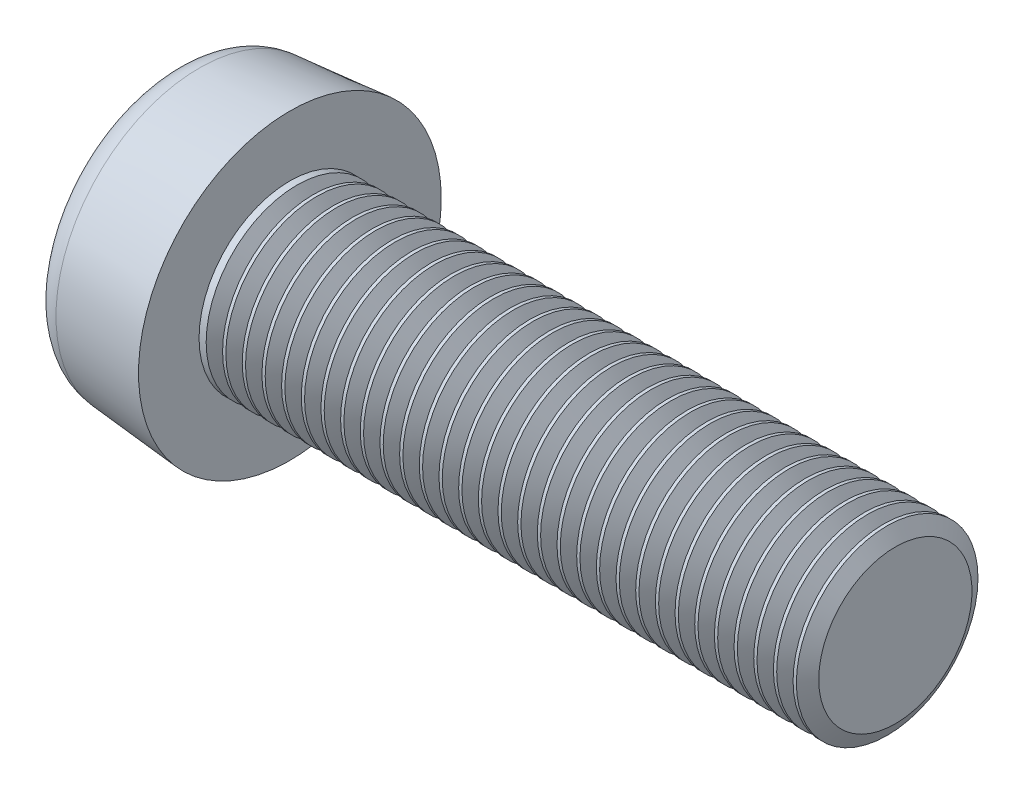
from build123d import *

# Parameters (mm, degrees)
SKETCH1_R        = 5
BASEHEAD_DEPTH   = 3.9
BASEHEAD_DRAFT   = -5
SKETCH8_W        = 20
SKETCH8_H        = 3
SOCKET_DEPTH     = 2
HEADFILLET2_R    = 1
LPATTERN10_COUNT = 31
LPATTERN10_PITCH = 0.6498


with BuildPart() as part:
    # Sketch1 → BaseHead (with draft: the straight prism first)
    with BuildSketch(Plane(origin=(3.9, 0, 0), x_dir=(0, 0, -1), z_dir=(1, 0, 0))):
        Circle(SKETCH1_R)
    extrude(amount=-BASEHEAD_DEPTH)
    # BaseHead: the draft: its side faces are tilted about the plane it starts from
    basehead_sides = [part.faces().sort_by_distance(p)[0] for p in [
        (1.95, 0, 5),
    ]]
    draft(basehead_sides, Plane(origin=(3.9, 0, 0), x_dir=(0, 0, -1), z_dir=(1, 0, 0)), BASEHEAD_DRAFT)

    # Sketch8 → Revolve1 (revolve)
    with BuildSketch(Plane.XY, mode=Mode.PRIVATE) as revolve1_sk:
        with Locations((13.9, 1.5)):
            Rectangle(SKETCH8_W, SKETCH8_H)
    revolve(revolve1_sk.sketch.rotate(Axis((0, 0, 0), (1, 0, 0)), 90), axis=Axis((0, 0, 0), (1, 0, 0)))

    # Sketch4 → Socket (cut)
    with BuildSketch(Plane(origin=(0, 0, 0), x_dir=(0, 0, -1), z_dir=(1, 0, 0))):
        with BuildLine():
            add(Edge.make_bspline(
                [(1.0375, 1.797002713), (1.436538462, 1.56661775), (2.394230769, 1.382309779), (1.915384615, 0), (2.394230769, -1.382309779), (0.957692308, -1.658771735), (0, -2.764619558), (-0.957692308, -1.658771735), (-2.394230769, -1.382309779), (-1.915384615, 0), (-2.394230769, 1.382309779), (-0.957692308, 1.658771735), (0, 2.764619558), (0.638461538, 2.027387676), (1.0375, 1.797002713)],
                knots=[0, 0, 0, 0, 0.083333333, 0.166666667, 0.25, 0.333333333, 0.416666667, 0.5, 0.583333333, 0.666666667, 0.75, 0.833333333, 0.916666667, 1, 1, 1, 1], degree=3))
        make_face()
    extrude(amount=SOCKET_DEPTH, mode=Mode.SUBTRACT)

    # Sketch5 → Cut-Loft1 section 0
    with BuildSketch(Plane.ZY.offset(-2), mode=Mode.PRIVATE) as cut_loft1_s0:
        with BuildLine():
            add(Edge.make_bspline(
                [(-1.0375, 1.797002713), (-1.436538462, 1.56661775), (-2.394230769, 1.382309779), (-1.915384615, 0), (-2.394230769, -1.382309779), (-0.957692308, -1.658771735), (0, -2.764619558), (0.957692308, -1.658771735), (2.394230769, -1.382309779), (1.915384615, 0), (2.394230769, 1.382309779), (0.957692308, 1.658771735), (0, 2.764619558), (-0.638461538, 2.027387676), (-1.0375, 1.797002713)],
                knots=[0, 0, 0, 0, 0.083333333, 0.166666667, 0.25, 0.333333333, 0.416666667, 0.5, 0.583333333, 0.666666667, 0.75, 0.833333333, 0.916666667, 1, 1, 1, 1], degree=3))
        make_face()
    loft([Vertex(2.666666667, 0, 0), cut_loft1_s0.sketch], mode=Mode.SUBTRACT)

    # HeadFillet2
    headfillet2_edges = [part.edges().sort_by_distance(p)[0] for p in [
        (0, 0, 4.658794212),
    ]]
    fillet(headfillet2_edges, radius=HEADFILLET2_R)

    # Sketch9 → Cut-Revolve10 (revolve, cut)
    with BuildSketch(Plane.XY, mode=Mode.PRIVATE) as cut_revolve10_sk:
        Polygon((23.9, 2.531047244), (24.17075, 3), (24.17075, 3.5415), (23.62925, 3.5415), (23.62925, 3), align=None)
    cut_revolve10 = revolve(cut_revolve10_sk.sketch.rotate(Axis((0, 0, 0), (1, 0, 0)), 90), axis=Axis((0, 0, 0), (1, 0, 0)), mode=Mode.SUBTRACT)

    # LPattern10: Cut-Revolve10 ×31
    with Locations(*[(-i * LPATTERN10_PITCH, 0, 0) for i in range(1, LPATTERN10_COUNT)]):
        add(cut_revolve10, mode=Mode.SUBTRACT)


solid = part.part
